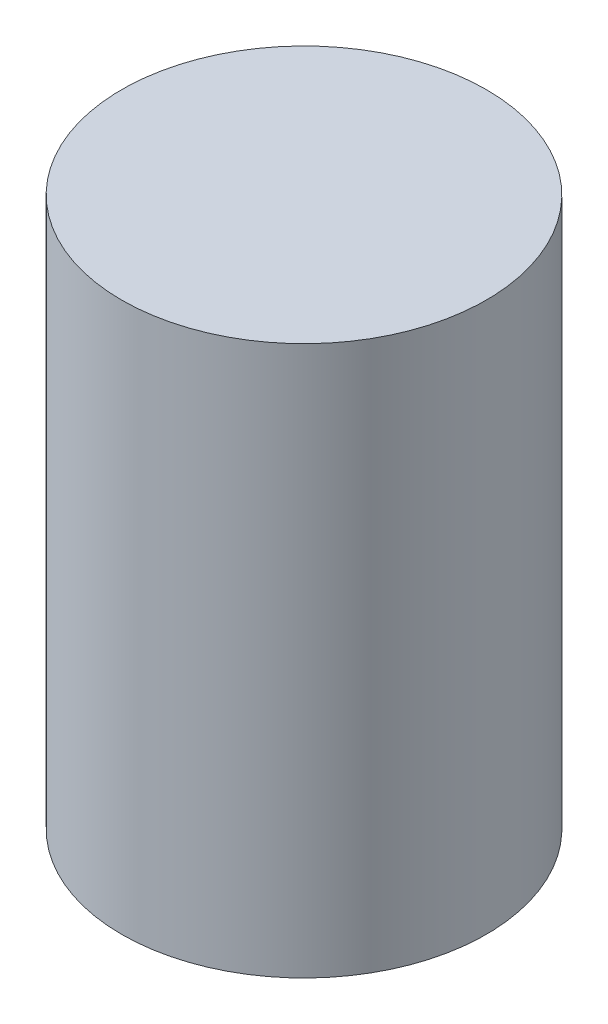
from build123d import *

# Parameters (mm, degrees)
SKETCH1_R           = 3.05
BOSS_EXTRUDE1_DEPTH = 9.19


with BuildPart() as part:
    # Sketch1 → Boss-Extrude1 (new body)
    with BuildSketch(Plane(origin=(0, 0, 0), x_dir=(1, 0, 0), z_dir=(0, 1, 0))):
        Circle(SKETCH1_R)
    extrude(amount=BOSS_EXTRUDE1_DEPTH)


solid = part.part
